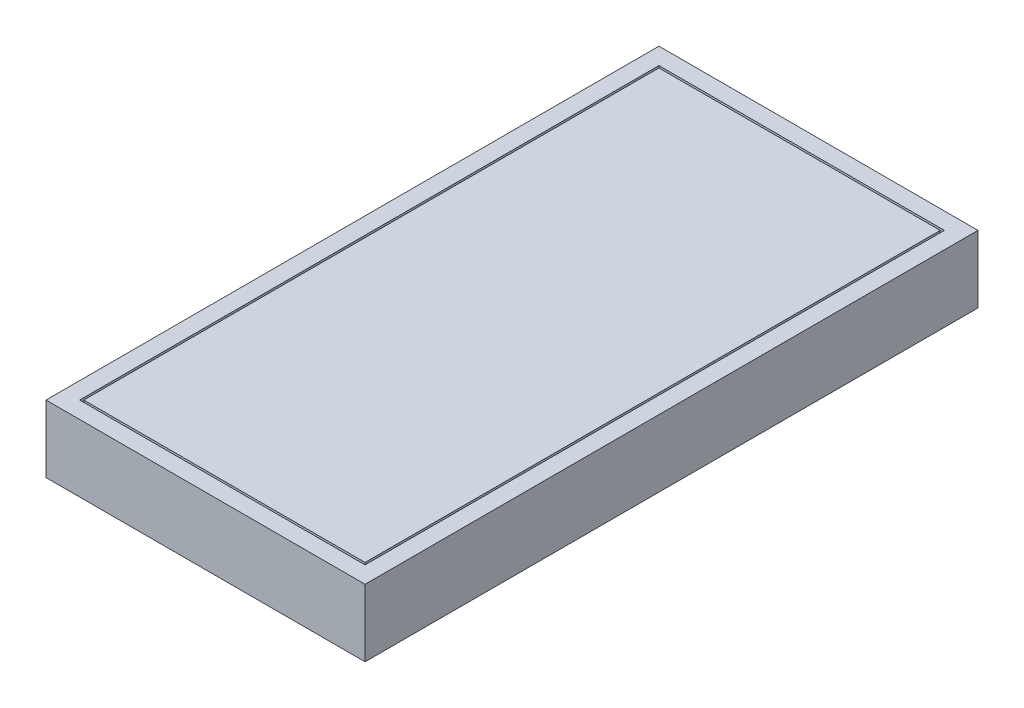
from build123d import *

# Parameters (mm, degrees)
SKETCH1_W           = 380
SKETCH1_H           = 730
BOSS_EXTRUDE1_DEPTH = 80
SKETCH2_W           = 340
SKETCH2_H           = 690
CUT_EXTRUDE1_DEPTH  = 11
SKETCH3_W           = 335
SKETCH3_H           = 685
BOSS_EXTRUDE2_DEPTH = 11


with BuildPart() as part:
    # Sketch1 → Boss-Extrude1 (new body)
    with BuildSketch(Plane.XZ.offset(60)):
        with Locations((0, 365)):
            Rectangle(SKETCH1_W, SKETCH1_H)
    extrude(amount=-BOSS_EXTRUDE1_DEPTH)

    # Sketch2 → Cut-Extrude1 (cut)
    with BuildSketch(Plane(origin=(0, 20, 0), x_dir=(-1, 0, 0), z_dir=(0, 1, 0))):
        with Locations((0, 365)):
            Rectangle(SKETCH2_W, SKETCH2_H)
    extrude(amount=-CUT_EXTRUDE1_DEPTH, mode=Mode.SUBTRACT)

    # Sketch3 → Boss-Extrude2 (add)
    with BuildSketch(Plane(origin=(0, 9, 0), x_dir=(-1, 0, 0), z_dir=(0, 1, 0))):
        with Locations((0, 365)):
            Rectangle(SKETCH3_W, SKETCH3_H)
    extrude(amount=BOSS_EXTRUDE2_DEPTH)


solid = part.part
